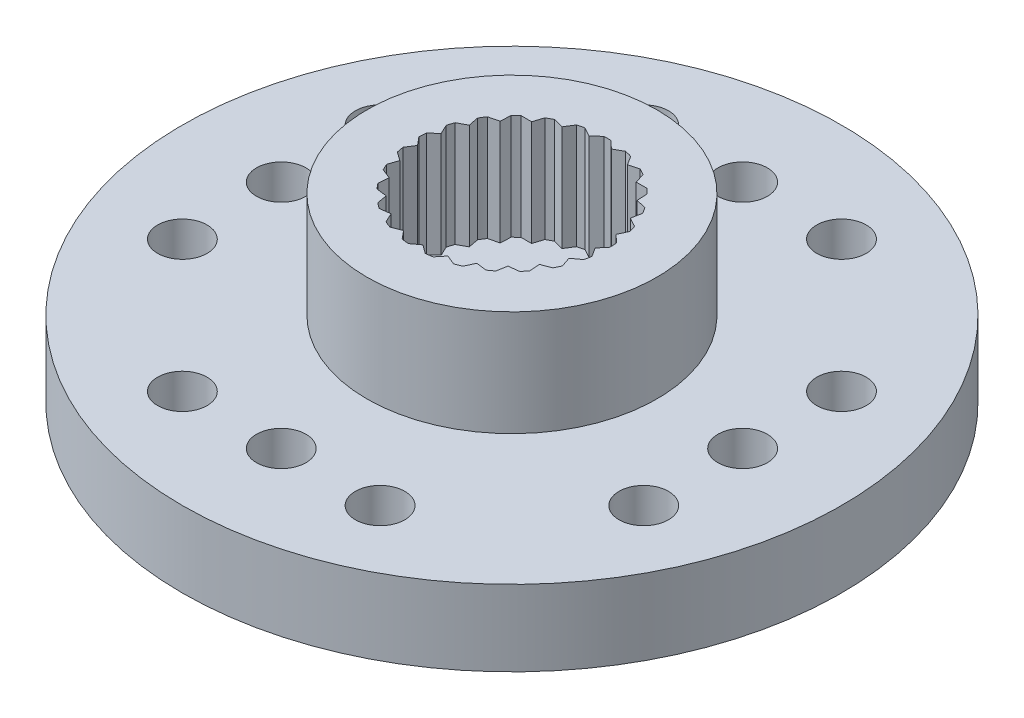
from build123d import *

# Parameters (mm, degrees)
SKETCH2_R           = 6
SKETCH2_R_2         = 1.5
BOSS_EXTRUDE1_DEPTH = 1.15
SKETCH3_R           = 4.4
BOSS_EXTRUDE2_DEPTH = 3.2
SKETCH5_R           = 10
SKETCH5_R_2         = 0.75
SKETCH5_R_3         = 1.5
BOSS_EXTRUDE4_DEPTH = 1.15


with BuildPart() as part:
    # Sketch2 → Boss-Extrude1 (new body, symmetric)
    with BuildSketch(Plane(origin=(0, 0, 0), x_dir=(1, 0, 0), z_dir=(0, 1, 0))):
        Circle(SKETCH2_R)
        Circle(SKETCH2_R_2, mode=Mode.SUBTRACT)
    extrude(amount=BOSS_EXTRUDE1_DEPTH, both=True)

    # Sketch3 → Boss-Extrude2 (add)
    with BuildSketch(Plane(origin=(0, 1.15, 0), x_dir=(1, 0, 0), z_dir=(0, 1, 0))):
        Circle(SKETCH3_R)
        with BuildLine():
            Line((0.107421435, 2.898009771), (0.338399731, 2.678709694))
            Line((0.338399731, 2.678709694), (0.61665913, 2.83367809))
            ThreePointArc((0.61665913, 2.83367809), (0.721200673, 2.808891167), (0.824752316, 2.780248841))
            Line((0.824752316, 2.780248841), (0.993936292, 2.510396512))
            Line((0.993936292, 2.510396512), (1.301992734, 2.591295993))
            ThreePointArc((1.301992734, 2.591295993), (1.397085655, 2.541289372), (1.490260976, 2.48779465))
            Line((1.490260976, 2.48779465), (1.587020181, 2.184345885))
            Line((1.587020181, 2.184345885), (1.905517346, 2.186093238))
            ThreePointArc((1.905517346, 2.186093238), (1.985186607, 2.11400902), (2.062131058, 2.039023173))
            Line((2.062131058, 2.039023173), (2.080385755, 1.721044772))
            Line((2.080385755, 1.721044772), (2.389311295, 1.643530205))
            ThreePointArc((2.389311295, 1.643530205), (2.448550984, 1.553897705), (2.504429862, 1.46213237))
            Line((2.504429862, 1.46213237), (2.443033042, 1.149604087))
            Line((2.443033042, 1.149604087), (2.722976028, 0.997698125))
            ThreePointArc((2.722976028, 0.997698125), (2.758063897, 0.896149284), (2.789366126, 0.793370413))
            Line((2.789366126, 0.793370413), (2.652175577, 0.505929549))
            Line((2.652175577, 0.505929549), (2.885546163, 0.289177003))
            ThreePointArc((2.885546163, 0.289177003), (2.894277512, 0.182092507), (2.899036259, 0.074758075))
            Line((2.899036259, 0.074758075), (2.694672167, -0.169534403))
            Line((2.694672167, -0.169534403), (2.866806821, -0.437514174))
            ThreePointArc((2.866806821, -0.437514174), (2.848633027, -0.543405812), (2.826549281, -0.648551587))
            Line((2.826549281, -0.648551587), (2.567852594, -0.834345885))
            Line((2.567852594, -0.834345885), (2.667935462, -1.136714727))
            ThreePointArc((2.667935462, -1.136714727), (2.623998452, -1.234759946), (2.576459817, -1.331110368))
            Line((2.576459817, -1.331110368), (2.279685399, -1.446732346))
            Line((2.279685399, -1.446732346), (2.301427906, -1.764491312))
            ThreePointArc((2.301427906, -1.764491312), (2.234488404, -1.84852957), (2.164481907, -1.930030589))
            Line((2.164481907, -1.930030589), (1.848277186, -1.968215294))
            Line((1.848277186, -1.968215294), (1.790313171, -2.281398419))
            ThreePointArc((1.790313171, -2.281398419), (1.704577232, -2.346149284), (1.616501638, -2.40767989))
            Line((1.616501638, -2.40767989), (1.30073492, -2.366028036))
            Line((1.30073492, -2.366028036), (1.166706475, -2.654956874))
            ThreePointArc((1.166706475, -2.654956874), (1.067561203, -2.696351809), (0.966950626, -2.734045809))
            Line((0.966950626, -2.734045809), (0.671462695, -2.615174535))
            Line((0.671462695, -2.615174535), (0.469791321, -2.861694623))
            ThreePointArc((0.469791321, -2.861694623), (0.363466377, -2.877132634), (0.25664255, -2.888621575))
            Line((0.25664255, -2.888621575), (0, -2.7))
            Line((0, -2.7), (-0.25664255, -2.888621575))
            ThreePointArc((-0.25664255, -2.888621575), (-0.363466377, -2.877132634), (-0.469791321, -2.861694623))
            Line((-0.469791321, -2.861694623), (-0.671462695, -2.615174535))
            Line((-0.671462695, -2.615174535), (-0.966950626, -2.734045809))
            ThreePointArc((-0.966950626, -2.734045809), (-1.067561203, -2.696351809), (-1.166706475, -2.654956874))
            Line((-1.166706475, -2.654956874), (-1.30073492, -2.366028036))
            Line((-1.30073492, -2.366028036), (-1.616501638, -2.40767989))
            ThreePointArc((-1.616501638, -2.40767989), (-1.704577232, -2.346149284), (-1.790313171, -2.281398419))
            Line((-1.790313171, -2.281398419), (-1.848277186, -1.968215294))
            Line((-1.848277186, -1.968215294), (-2.164481907, -1.930030589))
            ThreePointArc((-2.164481907, -1.930030589), (-2.234488404, -1.84852957), (-2.301427906, -1.764491312))
            Line((-2.301427906, -1.764491312), (-2.279685399, -1.446732346))
            Line((-2.279685399, -1.446732346), (-2.576459817, -1.331110368))
            ThreePointArc((-2.576459817, -1.331110368), (-2.623998452, -1.234759946), (-2.667935462, -1.136714727))
            Line((-2.667935462, -1.136714727), (-2.567852594, -0.834345885))
            Line((-2.567852594, -0.834345885), (-2.826549281, -0.648551587))
            ThreePointArc((-2.826549281, -0.648551587), (-2.848633027, -0.543405812), (-2.866806821, -0.437514174))
            Line((-2.866806821, -0.437514174), (-2.694672167, -0.169534403))
            Line((-2.694672167, -0.169534403), (-2.899036259, 0.074758075))
            ThreePointArc((-2.899036259, 0.074758075), (-2.894277512, 0.182092507), (-2.885546163, 0.289177003))
            Line((-2.885546163, 0.289177003), (-2.652175577, 0.505929549))
            Line((-2.652175577, 0.505929549), (-2.789366126, 0.793370413))
            ThreePointArc((-2.789366126, 0.793370413), (-2.758063897, 0.896149284), (-2.722976028, 0.997698125))
            Line((-2.722976028, 0.997698125), (-2.443033042, 1.149604087))
            Line((-2.443033042, 1.149604087), (-2.504429862, 1.46213237))
            ThreePointArc((-2.504429862, 1.46213237), (-2.448550984, 1.553897705), (-2.389311295, 1.643530205))
            Line((-2.389311295, 1.643530205), (-2.080385755, 1.721044772))
            Line((-2.080385755, 1.721044772), (-2.062131058, 2.039023173))
            ThreePointArc((-2.062131058, 2.039023173), (-1.985186607, 2.11400902), (-1.905517346, 2.186093238))
            Line((-1.905517346, 2.186093238), (-1.587020181, 2.184345885))
            Line((-1.587020181, 2.184345885), (-1.490260976, 2.48779465))
            ThreePointArc((-1.490260976, 2.48779465), (-1.397085655, 2.541289372), (-1.301992734, 2.591295993))
            Line((-1.301992734, 2.591295993), (-0.993936292, 2.510396512))
            Line((-0.993936292, 2.510396512), (-0.824752316, 2.780248841))
            ThreePointArc((-0.824752316, 2.780248841), (-0.721200673, 2.808891167), (-0.61665913, 2.83367809))
            Line((-0.61665913, 2.83367809), (-0.338399731, 2.678709694))
            Line((-0.338399731, 2.678709694), (-0.107421435, 2.898009771))
            ThreePointArc((-0.107421435, 2.898009771), (0, 2.9), (0.107421435, 2.898009771))
        make_face(mode=Mode.SUBTRACT)
    extrude(amount=BOSS_EXTRUDE2_DEPTH)

    # Sketch5 → Boss-Extrude4 (add, symmetric)
    with BuildSketch(Plane(origin=(0, 0, 0), x_dir=(1, 0, 0), z_dir=(0, 1, 0))):
        Circle(SKETCH5_R)
        with Locations((0, 7)):
            Circle(SKETCH5_R_2, mode=Mode.SUBTRACT)
        with Locations((-3, 7)):
            Circle(SKETCH5_R_2, mode=Mode.SUBTRACT)
        with Locations((3, 7)):
            Circle(SKETCH5_R_2, mode=Mode.SUBTRACT)
        with Locations((7, 3)):
            Circle(SKETCH5_R_2, mode=Mode.SUBTRACT)
        with Locations((7, 0)):
            Circle(SKETCH5_R_2, mode=Mode.SUBTRACT)
        with Locations((7, -3)):
            Circle(SKETCH5_R_2, mode=Mode.SUBTRACT)
        with Locations((3, -7)):
            Circle(SKETCH5_R_2, mode=Mode.SUBTRACT)
        with Locations((0, -7)):
            Circle(SKETCH5_R_2, mode=Mode.SUBTRACT)
        with Locations((-3, -7)):
            Circle(SKETCH5_R_2, mode=Mode.SUBTRACT)
        with Locations((-7, -3)):
            Circle(SKETCH5_R_2, mode=Mode.SUBTRACT)
        with Locations((-7, 0)):
            Circle(SKETCH5_R_2, mode=Mode.SUBTRACT)
        with Locations((-7, 3)):
            Circle(SKETCH5_R_2, mode=Mode.SUBTRACT)
        Circle(SKETCH5_R_3, mode=Mode.SUBTRACT)
    extrude(amount=BOSS_EXTRUDE4_DEPTH, both=True)


solid = part.part
